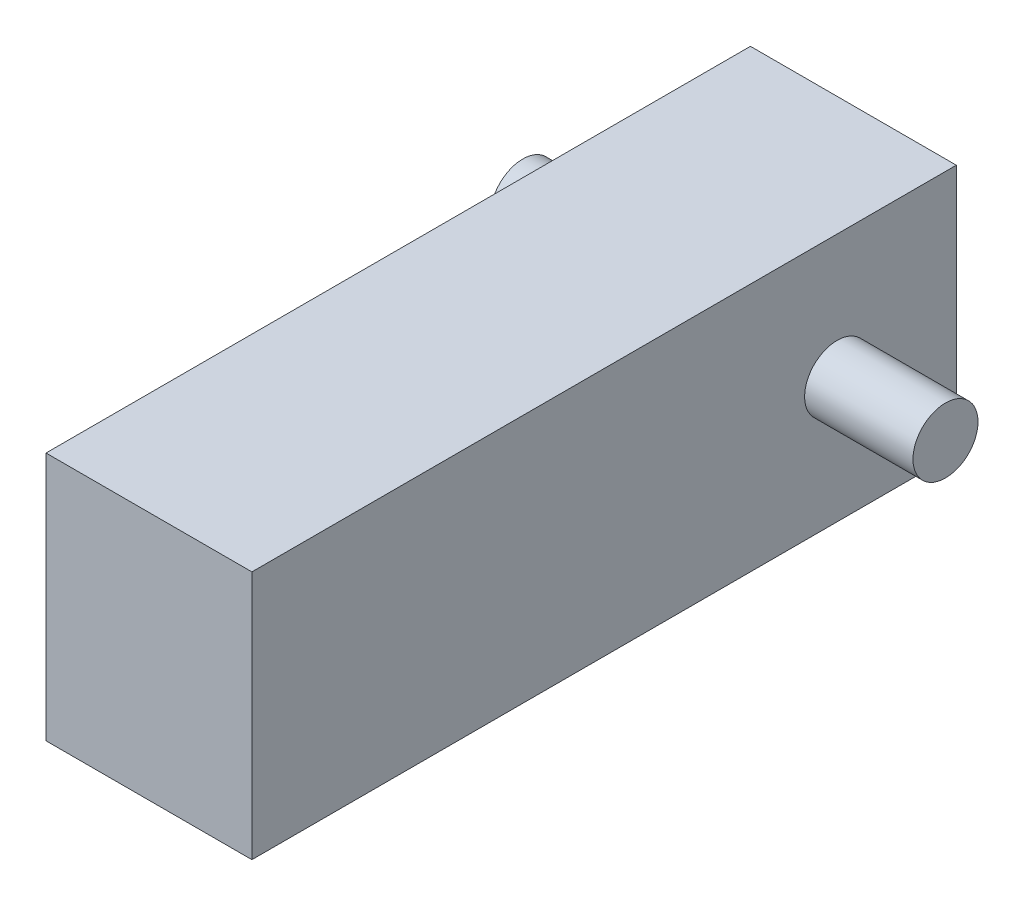
from build123d import *

# Parameters (mm, degrees)
CROQUIS1_W              = 19
CROQUIS1_H              = 65
SALIENTE_EXTRUIR1_DEPTH = 23
CROQUIS2_R              = 3
SALIENTE_EXTRUIR2_DEPTH = 10
CROQUIS3_R              = 3
SALIENTE_EXTRUIR3_DEPTH = 39
CROQUIS4_R              = 1.5
SALIENTE_EXTRUIR4_DEPTH = 1


with BuildPart() as part:
    # Croquis1 → Saliente-Extruir1 (new body)
    with BuildSketch(Plane(origin=(0, 0, 0), x_dir=(1, 0, 0), z_dir=(0, 1, 0))):
        Rectangle(CROQUIS1_W, CROQUIS1_H)
    extrude(amount=SALIENTE_EXTRUIR1_DEPTH)

    # Croquis2 → Saliente-Extruir2 (add)
    with BuildSketch(Plane(origin=(9.5, 0, 0), x_dir=(0, 0, -1), z_dir=(1, 0, 0))):
        with Locations((21.5, 11.5)):
            Circle(CROQUIS2_R)
    extrude(amount=SALIENTE_EXTRUIR2_DEPTH)

    # Croquis3 → Saliente-Extruir3 (add)
    with BuildSketch(Plane(origin=(19.5, 0, 0), x_dir=(0, 0, -1), z_dir=(1, 0, 0))):
        with Locations((21.5, 11.5)):
            Circle(CROQUIS3_R)
    extrude(amount=-SALIENTE_EXTRUIR3_DEPTH)

    # Croquis4 → Saliente-Extruir4 (add)
    with BuildSketch(Plane.ZY.offset(9.5)):
        with Locations((-9.5, 11.962831391)):
            Circle(CROQUIS4_R)
    extrude(amount=SALIENTE_EXTRUIR4_DEPTH)


solid = part.part
